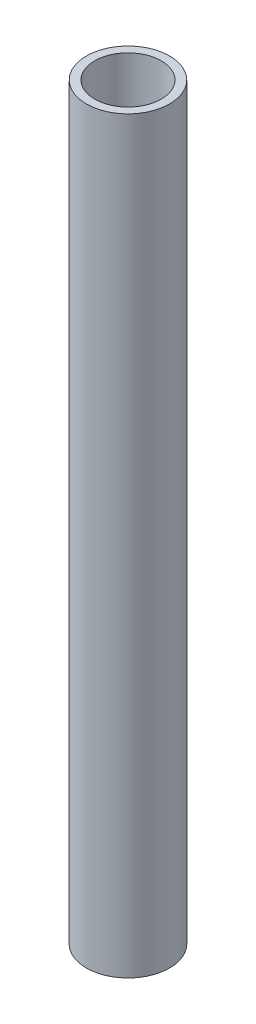
from build123d import *

# Parameters (mm, degrees)
CROQUIS1_R              = 25
CROQUIS1_R_2            = 20
SALIENTE_EXTRUIR1_DEPTH = 450


with BuildPart() as part:
    # Croquis1 → Saliente-Extruir1 (new body)
    with BuildSketch(Plane(origin=(0, 0, 0), x_dir=(1, 0, 0), z_dir=(0, 1, 0))):
        Circle(CROQUIS1_R)
        Circle(CROQUIS1_R_2, mode=Mode.SUBTRACT)
    extrude(amount=SALIENTE_EXTRUIR1_DEPTH)


solid = part.part
